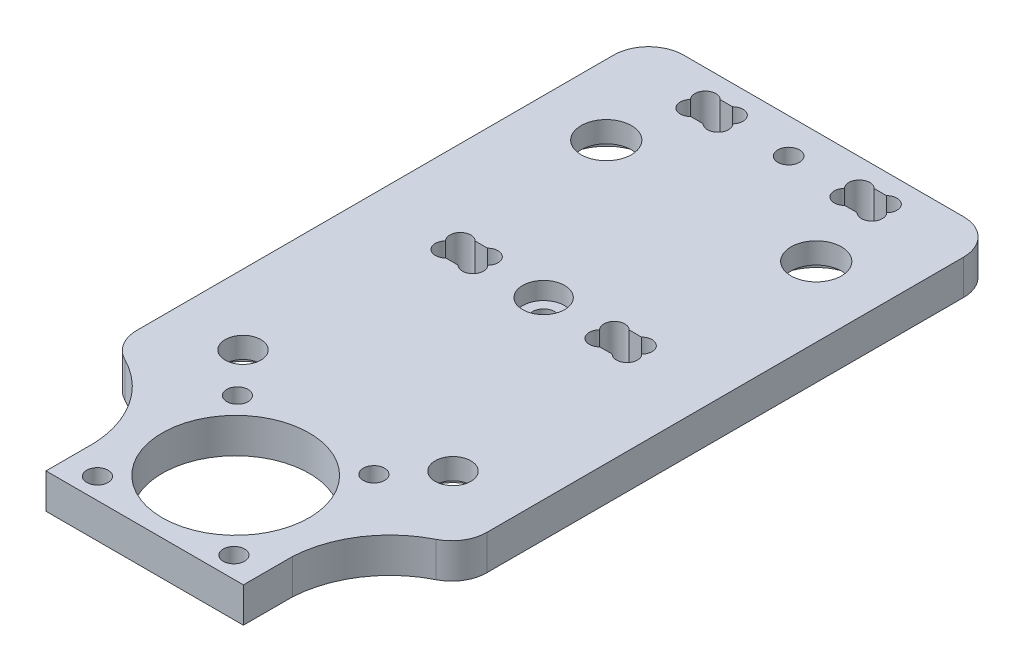
from build123d import *

# Parameters (mm, degrees)
CROQUIS1_W              = 50
CROQUIS1_H              = 97
SALIENTE_EXTRUIR1_DEPTH = 5
CORTAR_EXTRUIR1_DEPTH   = 6
CROQUIS2_R              = 3.6
CROQUIS2_R_2            = 2.55
CORTAR_EXTRUIR2_DEPTH   = 6
CROQUIS4_R              = 6
CROQUIS4_R_2            = 5.05
CORTAR_EXTRUIR3_DEPTH   = 2
REDONDEO1_R             = 5
CROQUIS5_R              = 1.55
CROQUIS5_W              = 6
CROQUIS5_H              = 4.2
CORTAR_EXTRUIR4_DEPTH   = 6
CORTAR_EXTRUIR6_DEPTH   = 6
CROQUIS14_R             = 3
CORTAR_EXTRUIR9_DEPTH   = 2.5
CROQUIS18_R             = 10.5
CROQUIS18_R_2           = 1.525
CORTAR_EXTRUIR10_DEPTH  = 6


with BuildPart() as part:
    # Croquis1 → Saliente-Extruir1 (new body)
    with BuildSketch(Plane(origin=(0, 0, 0), x_dir=(1, 0, 0), z_dir=(0, 1, 0))):
        Rectangle(CROQUIS1_W, CROQUIS1_H)
    extrude(amount=SALIENTE_EXTRUIR1_DEPTH)

    # Croquis3 → Cortar-Extruir1 (cut, through all)
    with BuildSketch(Plane(origin=(0, 5, 0), x_dir=(1, 0, 0), z_dir=(0, 1, 0))):
        with BuildLine():
            Line((-14.1, -41.5), (-14.1, -48.5))
            Line((-14.1, -48.5), (-25, -48.5))
            Line((-25, -48.5), (-25, -28.05))
            ThreePointArc((-25, -28.05), (-17.369189497, -33.007651712), (-14.1, -41.5))
        make_face()
        with BuildLine():
            Line((25, -48.5), (14.1, -48.5))
            Line((14.1, -48.5), (14.1, -41.5))
            ThreePointArc((14.1, -41.5), (17.369189497, -33.007651712), (25, -28.05))
            Line((25, -28.05), (25, -48.5))
        make_face()
    extrude(amount=-CORTAR_EXTRUIR1_DEPTH, mode=Mode.SUBTRACT)

    # Croquis2 → Cortar-Extruir2 (cut, through all)
    with BuildSketch(Plane(origin=(0, 5, 0), x_dir=(1, 0, 0), z_dir=(0, 1, 0))):
        with Locations((-15, 32.45)):
            Circle(CROQUIS2_R)
        with Locations((15, 32.45)):
            Circle(CROQUIS2_R)
        with Locations((15, -19.45)):
            Circle(CROQUIS2_R_2)
        with Locations((-15, -19.45)):
            Circle(CROQUIS2_R_2)
    extrude(amount=-CORTAR_EXTRUIR2_DEPTH, mode=Mode.SUBTRACT)

    # Croquis4 → Cortar-Extruir3 (cut)
    with BuildSketch(Plane.XZ):
        with Locations((15, -32.45)):
            Circle(CROQUIS4_R)
        with Locations((-15, -32.45)):
            Circle(CROQUIS4_R)
        with Locations((-15, 19.45)):
            Circle(CROQUIS4_R_2)
        with Locations((15, 19.45)):
            Circle(CROQUIS4_R_2)
    extrude(amount=-CORTAR_EXTRUIR3_DEPTH, mode=Mode.SUBTRACT)

    # Redondeo1
    redondeo1_edges = [part.edges().sort_by_distance(p)[0] for p in [
        (-25, 2.5, 28.05),
        (25, 2.5, 28.05),
        (-25, 2.5, -48.5),
        (25, 2.5, -48.5),
    ]]
    fillet(redondeo1_edges, radius=REDONDEO1_R)

    # Croquis5 → Cortar-Extruir4 (cut, through all)
    with BuildSketch(Plane(origin=(0, 5, 0), x_dir=(1, 0, 0), z_dir=(0, 1, 0))):
        with Locations((0, 43.5)):
            Circle(CROQUIS5_R)
        with Locations((-11, 43.5)):
            Rectangle(CROQUIS5_W, CROQUIS5_H)
        with Locations((11, 43.5)):
            Rectangle(CROQUIS5_W, CROQUIS5_H)
    cortar_extruir4 = extrude(amount=-CORTAR_EXTRUIR4_DEPTH, mode=Mode.SUBTRACT)

    # Croquis8 → Cortar-Extruir6 (cut, through all)
    with BuildSketch(Plane(origin=(0, 5, 0), x_dir=(1, 0, 0), z_dir=(0, 1, 0))):
        with BuildLine():
            Line((-11.878679656, 45.6), (-10.121320344, 45.6))
            ThreePointArc((-10.121320344, 45.6), (-8.010608171, 45.610503119), (-7.979099854, 43.5))
            ThreePointArc((-7.979099854, 43.5), (-8.010608171, 41.389496881), (-10.121320344, 41.4))
            Line((-10.121320344, 41.4), (-11.878679656, 41.4))
            ThreePointArc((-11.878679656, 41.4), (-13.989391829, 41.389496881), (-14.020900146, 43.5))
            ThreePointArc((-14.020900146, 43.5), (-13.989391829, 45.610503119), (-11.878679656, 45.6))
        make_face()
        with BuildLine():
            Line((10.121320344, 41.4), (11.878679656, 41.4))
            ThreePointArc((11.878679656, 41.4), (13.989391829, 41.389496881), (14.020900146, 43.5))
            ThreePointArc((14.020900146, 43.5), (13.989391829, 45.610503119), (11.878679656, 45.6))
            Line((11.878679656, 45.6), (10.121320344, 45.6))
            ThreePointArc((10.121320344, 45.6), (8.010608171, 45.610503119), (7.979099854, 43.5))
            ThreePointArc((7.979099854, 43.5), (8.010608171, 41.389496881), (10.121320344, 41.4))
        make_face()
    cortar_extruir6 = extrude(amount=-CORTAR_EXTRUIR6_DEPTH, mode=Mode.SUBTRACT)

    # Simetría1: Cortar-Extruir4, Cortar-Extruir6 across plane
    add(cortar_extruir4.mirror(Plane.XY.offset(-26)), mode=Mode.SUBTRACT)
    add(cortar_extruir6.mirror(Plane.XY.offset(-26)), mode=Mode.SUBTRACT)

    # Croquis14 → Cortar-Extruir9 (cut)
    with BuildSketch(Plane(origin=(0, 5, 0), x_dir=(1, 0, 0), z_dir=(0, 1, 0))):
        with Locations((0, 8.5)):
            Circle(CROQUIS14_R)
    extrude(amount=-CORTAR_EXTRUIR9_DEPTH, mode=Mode.SUBTRACT)

    # Croquis18 → Cortar-Extruir10 (cut, through all)
    with BuildSketch(Plane(origin=(0, 5, 0), x_dir=(1, 0, 0), z_dir=(0, 1, 0))):
        with Locations((0, -35.5)):
            Circle(CROQUIS18_R)
        with Locations((9.75, -45.5)):
            Circle(CROQUIS18_R_2)
        with Locations((-9.75, -45.5)):
            Circle(CROQUIS18_R_2)
        with Locations((9.75, -25.5)):
            Circle(CROQUIS18_R_2)
        with Locations((-9.75, -25.5)):
            Circle(CROQUIS18_R_2)
    extrude(amount=-CORTAR_EXTRUIR10_DEPTH, mode=Mode.SUBTRACT)


solid = part.part
